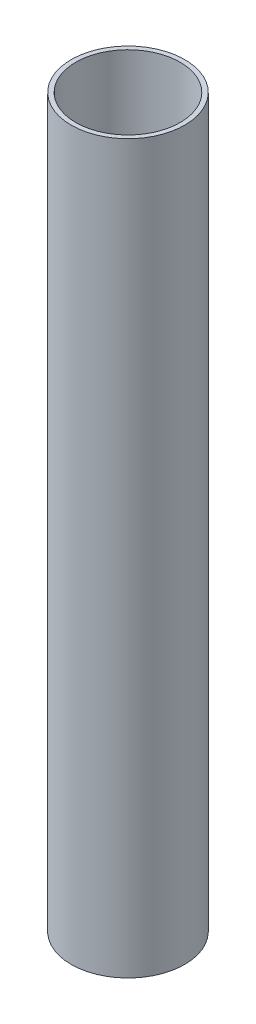
from build123d import *

# Parameters (mm, degrees)
SKETCH_1_R      = 12.5
SKETCH_1_R_2    = 11.5
EXTRUDE_1_DEPTH = 160


with BuildPart() as part:
    # Эскиз1 → Бобышка-Вытянуть1 (new body)
    with BuildSketch(Plane(origin=(0, 0, 0), x_dir=(1, 0, 0), z_dir=(0, 1, 0))):
        Circle(SKETCH_1_R)
        Circle(SKETCH_1_R_2, mode=Mode.SUBTRACT)
    extrude(amount=EXTRUDE_1_DEPTH)


solid = part.part
